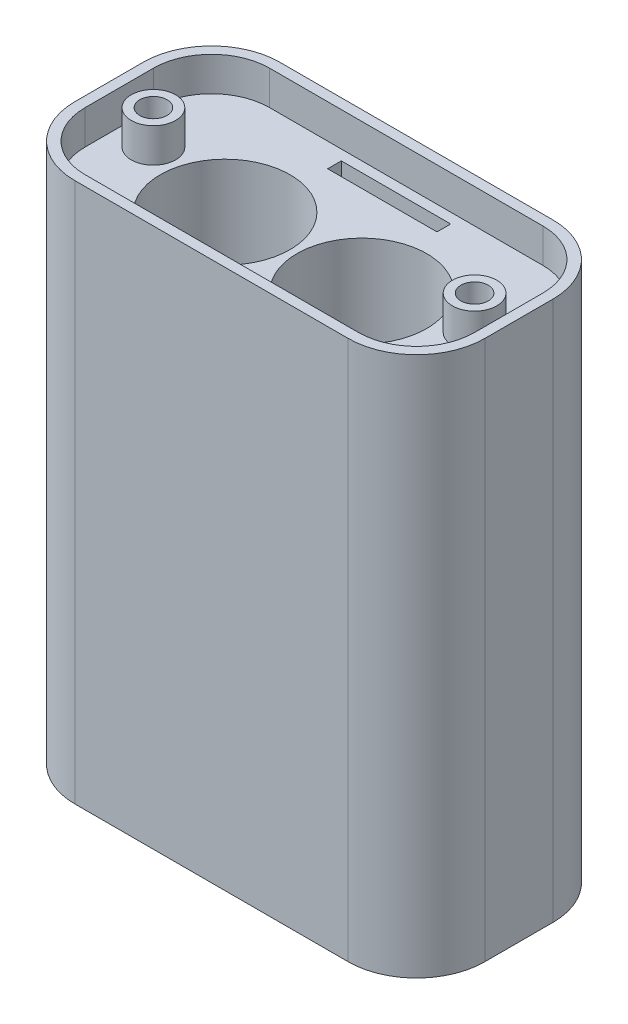
from build123d import *

# Parameters (mm, degrees)
SKETCH_1_R          = 9.5
EXTRUDE_1_DEPTH     = 10
SKETCH_2_R          = 8.5
SKETCH_2_R_2        = 9.5
CUT_EXTRUDE_1_DEPTH = 5
SKETCH_3_R          = 3.25
SKETCH_3_R_2        = 2
EXTRUDE_2_DEPTH     = 5
SKETCH_4_W          = 16
SKETCH_4_H          = 2
CUT_EXTRUDE_2_DEPTH = 6
EXTRUDE_3_DEPTH     = 29.5
SKETCH_8_W          = 40
SKETCH_8_H          = 59
CUT_EXTRUDE_4_DEPTH = 8
SKETCH_9_R          = 9.5
CUT_EXTRUDE_5_DEPTH = 70
SKETCH_10_R         = 3.25
SKETCH_10_R_2       = 2
EXTRUDE_4_DEPTH     = 6


with BuildPart() as part:
    # Эскиз1 → Бобышка-Вытянуть1 (new body)
    with BuildSketch(Plane(origin=(0, 0, 0), x_dir=(1, 0, 0), z_dir=(0, 1, 0))):
        with BuildLine():
            Line((-20, 18), (20, 18))
            ThreePointArc((20, 18), (27.071067812, 15.071067812), (30, 8))
            Line((30, 8), (30, -2))
            ThreePointArc((30, -2), (27.071067812, -9.071067812), (20, -12))
            Line((20, -12), (-20, -12))
            ThreePointArc((-20, -12), (-27.071067812, -9.071067812), (-30, -2))
            Line((-30, -2), (-30, 8))
            ThreePointArc((-30, 8), (-27.071067812, 15.071067812), (-20, 18))
        make_face()
        with Locations(Location((-10, 0, 0), (0, 0, 270))):
            Circle(SKETCH_1_R, mode=Mode.SUBTRACT)
        with Locations(Location((10, 0, 0), (0, 0, 90))):
            Circle(SKETCH_1_R, mode=Mode.SUBTRACT)
    extrude_1 = extrude(amount=EXTRUDE_1_DEPTH)

    # Эскиз2 → Вырез-Вытянуть1 (cut)
    with BuildSketch(Plane(origin=(0, 10, 0), x_dir=(1, 0, 0), z_dir=(0, 1, 0))):
        with Locations((-20, -2)):
            Circle(SKETCH_2_R)
        with Locations((-20, 8)):
            Circle(SKETCH_2_R)
        with Locations(Location((-10, 0, 0), (0, 0, 270))):
            Circle(SKETCH_2_R_2)
        with BuildLine():
            Line((20, 16.5), (-20, 16.5))
            ThreePointArc((-20, 16.5), (-14.492370575, 14.474258113), (-11.609926002, 9.362592497))
            ThreePointArc((-11.609926002, 9.362592497), (-3.878084328, 7.26444413), (-0.5, 0))
            ThreePointArc((-0.5, 0), (-5.086783087, -8.13082404), (-14.417957802, -8.410210988))
            ThreePointArc((-14.417957802, -8.410210988), (-17.01979811, -9.960426917), (-20, -10.5))
            Line((-20, -10.5), (20, -10.5))
            ThreePointArc((20, -10.5), (17.01979811, -9.960426917), (14.417957802, -8.410210988))
            ThreePointArc((14.417957802, -8.410210988), (0.616398255, -1.48257151), (11.609926002, 9.362592497))
            ThreePointArc((11.609926002, 9.362592497), (14.492370575, 14.474258113), (20, 16.5))
        make_face()
        with Locations((-20, -2)):
            Circle(SKETCH_2_R)
        with Locations((-20, 8)):
            Circle(SKETCH_2_R)
        with Locations(Location((-10, 0, 0), (0, 0, 270))):
            Circle(SKETCH_2_R_2)
        with Locations((-20, -2)):
            Circle(SKETCH_2_R)
        with Locations((-20, 8)):
            Circle(SKETCH_2_R)
        with Locations(Location((-10, 0, 0), (0, 0, 270))):
            Circle(SKETCH_2_R_2)
        with BuildLine():
            ThreePointArc((-26.873863542, 3), (-28.08324935, 5.371106707), (-28.5, 8))
            Line((-28.5, 8), (-28.5, -2))
            ThreePointArc((-28.5, -2), (-28.08324935, 0.628893293), (-26.873863542, 3))
        make_face()
        with Locations((20, -2)):
            Circle(SKETCH_2_R)
        with Locations((20, 8)):
            Circle(SKETCH_2_R)
        with Locations(Location((10, 0, 0), (0, 0, 90))):
            Circle(SKETCH_2_R_2)
        with Locations((20, -2)):
            Circle(SKETCH_2_R)
        with Locations((20, 8)):
            Circle(SKETCH_2_R)
        with Locations(Location((10, 0, 0), (0, 0, 90))):
            Circle(SKETCH_2_R_2)
        with Locations((20, -2)):
            Circle(SKETCH_2_R)
        with Locations((20, 8)):
            Circle(SKETCH_2_R)
        with Locations(Location((10, 0, 0), (0, 0, 90))):
            Circle(SKETCH_2_R_2)
        with BuildLine():
            Line((28.5, -2), (28.5, 8))
            ThreePointArc((28.5, 8), (28.08324935, 5.371106707), (26.873863542, 3))
            ThreePointArc((26.873863542, 3), (28.08324935, 0.628893293), (28.5, -2))
        make_face()
    cut_extrude_1 = extrude(amount=-CUT_EXTRUDE_1_DEPTH, mode=Mode.SUBTRACT)

    # Эскиз3 → Бобышка-Вытянуть2 (add)
    with BuildSketch(Plane(origin=(0, 5, 0), x_dir=(1, 0, 0), z_dir=(0, 1, 0))):
        with Locations(Location((-23.5, 3, 0), (0, 0, 270))):
            Circle(SKETCH_3_R)
        with Locations(Location((-23.5, 3, 0), (0, 0, 270))):
            Circle(SKETCH_3_R_2, mode=Mode.SUBTRACT)
        with Locations(Location((23.5, 3, 0), (0, 0, 90))):
            Circle(SKETCH_3_R)
        with Locations(Location((23.5, 3, 0), (0, 0, 90))):
            Circle(SKETCH_3_R_2, mode=Mode.SUBTRACT)
    extrude_2 = extrude(amount=EXTRUDE_2_DEPTH)

    # Эскиз4 → Вырез-Вытянуть2 (cut, through all)
    with BuildSketch(Plane(origin=(0, 5, 0), x_dir=(1, 0, 0), z_dir=(0, 1, 0))):
        with Locations((0, 14)):
            Rectangle(SKETCH_4_W, SKETCH_4_H)
    cut_extrude_2 = extrude(amount=-CUT_EXTRUDE_2_DEPTH, mode=Mode.SUBTRACT)

    # Эскиз5 → Бобышка-Вытянуть3 (add)
    with BuildSketch(Plane.XZ):
        with BuildLine():
            Line((30, -8), (30, 2))
            ThreePointArc((30, 2), (27.071067812, 9.071067812), (20, 12))
            Line((20, 12), (-20, 12))
            ThreePointArc((-20, 12), (-27.071067812, 9.071067812), (-30, 2))
            Line((-30, 2), (-30, -8))
            ThreePointArc((-30, -8), (-27.071067812, -15.071067812), (-20, -18))
            Line((-20, -18), (20, -18))
            ThreePointArc((20, -18), (27.071067812, -15.071067812), (30, -8))
        make_face()
    extrude_3 = extrude(amount=EXTRUDE_3_DEPTH)

    # Зеркальное отражение5: Бобышка-Вытянуть1, Вырез-Вытянуть1, Бобышка-Вытянуть2, Вырез-Вытянуть2, Бобышка-Вытянуть3 across plane
    add(extrude_1.mirror(Plane(origin=(0, -29.5, 0), x_dir=(0, 0, 1), z_dir=(0, -1, 0))))
    add(cut_extrude_1.mirror(Plane(origin=(0, -29.5, 0), x_dir=(0, 0, 1), z_dir=(0, -1, 0))), mode=Mode.SUBTRACT)
    add(extrude_2.mirror(Plane(origin=(0, -29.5, 0), x_dir=(0, 0, 1), z_dir=(0, -1, 0))))
    add(cut_extrude_2.mirror(Plane(origin=(0, -29.5, 0), x_dir=(0, 0, 1), z_dir=(0, -1, 0))), mode=Mode.SUBTRACT)
    add(extrude_3.mirror(Plane(origin=(0, -29.5, 0), x_dir=(0, 0, 1), z_dir=(0, -1, 0))))

    # Эскиз8 → Вырез-Вытянуть4 (cut)
    with BuildSketch(Plane(origin=(0, 0, -18), x_dir=(-1, 0, 0), z_dir=(0, 0, -1))):
        with Locations((0, -29.5)):
            Rectangle(SKETCH_8_W, SKETCH_8_H)
    extrude(amount=-CUT_EXTRUDE_4_DEPTH, mode=Mode.SUBTRACT)

    # Эскиз9 → Вырез-Вытянуть5 (cut, through all)
    with BuildSketch(Plane(origin=(0, -59, 0), x_dir=(-1, 0, 0), z_dir=(0, -1, 0))):
        with Locations(Location((10, 0, 0), (0, 0, 270))):
            Circle(SKETCH_9_R)
        with Locations(Location((-10, 0, 0), (0, 0, 270))):
            Circle(SKETCH_9_R)
    extrude(amount=-CUT_EXTRUDE_5_DEPTH, mode=Mode.SUBTRACT)

    # Эскиз10 → Бобышка-Вытянуть4 (add)
    with BuildSketch(Plane(origin=(0, 0, -10), x_dir=(-1, 0, 0), z_dir=(0, 0, -1))):
        with Locations((-13.5, -52.5)):
            Circle(SKETCH_10_R)
        with Locations((-13.5, -52.5)):
            Circle(SKETCH_10_R_2, mode=Mode.SUBTRACT)
        with Locations(Location((13.5, -52.5, 0), (0, 0, 180))):
            Circle(SKETCH_10_R)
        with Locations(Location((13.5, -52.5, 0), (0, 0, 180))):
            Circle(SKETCH_10_R_2, mode=Mode.SUBTRACT)
        with Locations((13.5, -6.5)):
            Circle(SKETCH_10_R)
        with Locations((13.5, -6.5)):
            Circle(SKETCH_10_R_2, mode=Mode.SUBTRACT)
        with Locations(Location((-13.5, -6.5, 0), (0, 0, 180))):
            Circle(SKETCH_10_R)
        with Locations(Location((-13.5, -6.5, 0), (0, 0, 180))):
            Circle(SKETCH_10_R_2, mode=Mode.SUBTRACT)
    extrude(amount=EXTRUDE_4_DEPTH)


solid = part.part
